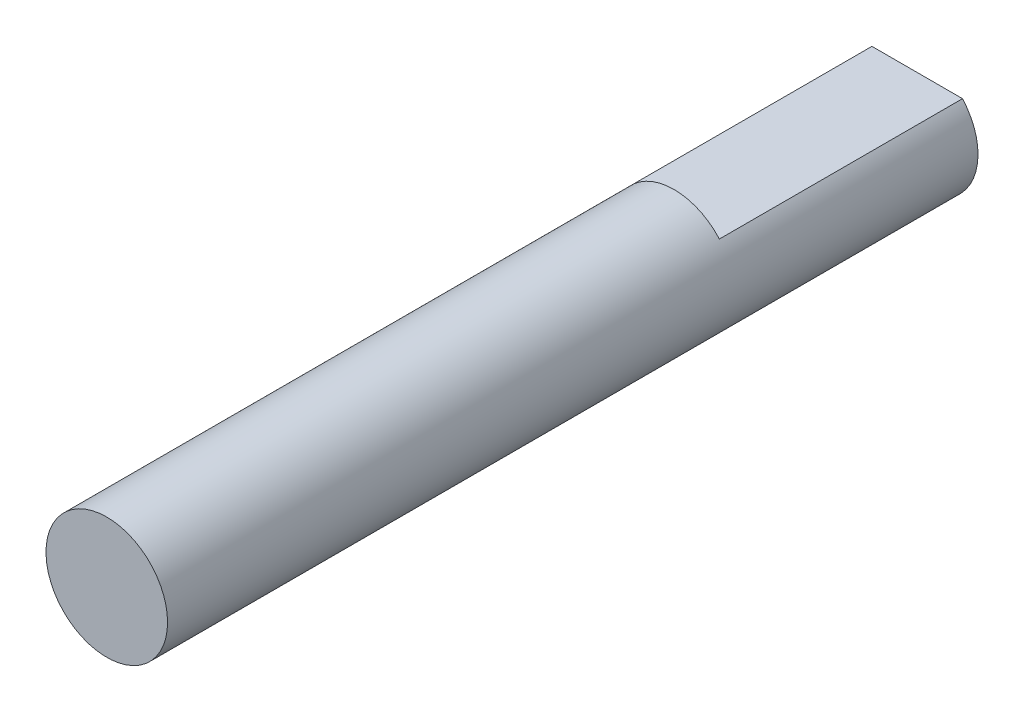
from build123d import *

# Parameters (mm, degrees)
BOSS_EXTRUDE1_DEPTH = 40
BOSS_EXTRUDE2_DEPTH = 28


with BuildPart() as part:
    # Sketch1 → Boss-Extrude1 (new body)
    with BuildSketch(Plane.XY):
        with BuildLine():
            Line((2.236067977, 2), (-2.236067977, 2))
            ThreePointArc((-2.236067977, 2), (0, -3), (2.236067977, 2))
        make_face()
    extrude(amount=BOSS_EXTRUDE1_DEPTH)

    # Sketch2 → Boss-Extrude2 (add)
    with BuildSketch(Plane.XY.offset(40)):
        with BuildLine():
            Line((-2.236067977, 2), (2.236067977, 2))
            ThreePointArc((2.236067977, 2), (0, 3), (-2.236067977, 2))
        make_face()
    extrude(amount=-BOSS_EXTRUDE2_DEPTH)


solid = part.part
